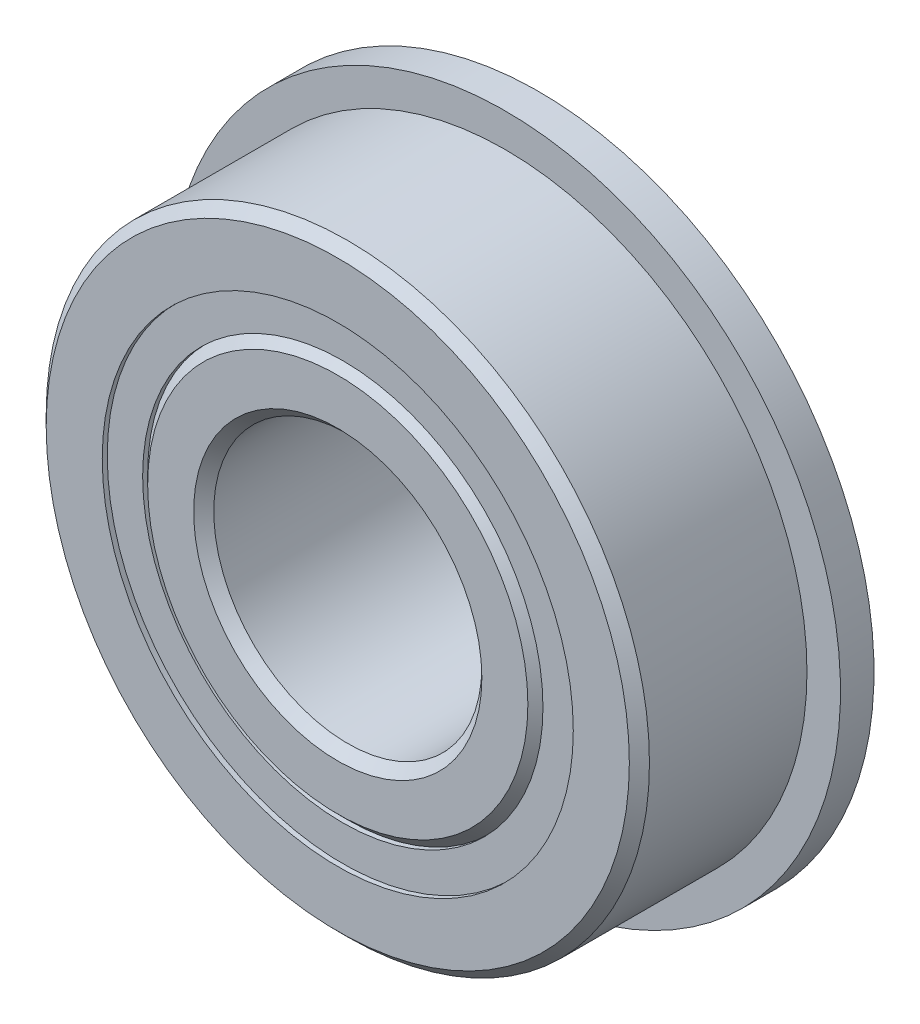
from build123d import *

# Parameters (mm, degrees)
CIRPATTERN1_COUNT = 12
SKETCH5_W         = 2.248094269
SKETCH5_H         = 1.674725274
SKETCH6_W         = 1.5875
SKETCH6_H         = 4.718887363


with BuildPart() as part:
    # Sketch1 → Revolve1 (revolve)
    with BuildSketch(Plane(origin=(0, 0, 0), x_dir=(0, 0, -1), z_dir=(1, 0, 0)), mode=Mode.PRIVATE) as revolve1_sk:
        with BuildLine():
            Line((4.28625, 14.2875), (-4.28625, 14.2875))
            Line((-4.28625, 14.2875), (-4.7625, 13.81125))
            Line((-4.7625, 13.81125), (-4.7625, 11.156112637))
            Line((-4.7625, 11.156112637), (-2.116666667, 11.156112637))
            ThreePointArc((-2.116666667, 11.156112637), (0, 12.595030731), (2.116666667, 11.156112637))
            Line((2.116666667, 11.156112637), (4.7625, 11.156112637))
            Line((4.7625, 11.156112637), (4.7625, 13.81125))
            Line((4.7625, 13.81125), (4.28625, 14.2875))
        make_face()
    revolve(revolve1_sk.sketch.rotate(Axis((0, 0, 4.7625), (0, 0, -1)), 90), axis=Axis((0, 0, 4.7625), (0, 0, -1)))  # turned: the seam where the file's is

    # Sketch6 → Revolve6 (revolve)
    with BuildSketch(Plane(origin=(0, 0, 0), x_dir=(0, 0, -1), z_dir=(1, 0, 0)), mode=Mode.PRIVATE) as revolve6_sk:
        with Locations((3.96875, 13.515556319)):
            Rectangle(SKETCH6_W, SKETCH6_H)
    revolve(revolve6_sk.sketch.rotate(Axis((0, 0, -4.7625), (0, 0, 1)), 270), axis=Axis((0, 0, -4.7625), (0, 0, 1)))  # turned: the seam where the file's is


with BuildPart() as body_2:
    # Sketch3 → Revolve3 (revolve)
    with BuildSketch(Plane(origin=(0, 0, 0), x_dir=(0, 0, -1), z_dir=(1, 0, 0)), mode=Mode.PRIVATE) as revolve3_sk:
        with BuildLine():
            Line((-4.7625, 6.82625), (-4.7625, 9.005137363))
            Line((-4.7625, 9.005137363), (-4.28625, 9.481387363))
            Line((-4.28625, 9.481387363), (-2.116666667, 9.481387363))
            ThreePointArc((-2.116666667, 9.481387363), (0, 8.042469269), (2.116666667, 9.481387363))
            Line((2.116666667, 9.481387363), (5.87375, 9.481387363))
            Line((5.87375, 9.481387363), (6.35, 9.005137363))
            Line((6.35, 9.005137363), (6.35, 6.82625))
            Line((6.35, 6.82625), (5.87375, 6.35))
            Line((5.87375, 6.35), (-4.28625, 6.35))
            Line((-4.28625, 6.35), (-4.7625, 6.82625))
        make_face()
    revolve(revolve3_sk.sketch.rotate(Axis((0, 0, 4.7625), (0, 0, -1)), 90), axis=Axis((0, 0, 4.7625), (0, 0, -1)))  # turned: the seam where the file's is


with BuildPart() as body_3:
    # Sketch4 → Revolve4 (revolve)
    with BuildSketch(Plane(origin=(0, 0, 0), x_dir=(0, 0, -1), z_dir=(1, 0, 0))):
        with BuildLine():
            Line((-2.276280731, 10.31875), (2.276280731, 10.31875))
            ThreePointArc((2.276280731, 10.31875), (0, 12.595030731), (-2.276280731, 10.31875))
        make_face()
    revolve(axis=Axis((0, 10.31875, 2.276280731), (0, 0, -1)))


with BuildPart() as cirpattern1_1:
    # CirPattern1: pattern copy
    add(body_3.part.rotate(Axis((0, 0, 0), (0, 0, 1)), 1 * 360 / CIRPATTERN1_COUNT))


with BuildPart() as cirpattern1_2:
    # CirPattern1: pattern copy
    add(body_3.part.rotate(Axis((0, 0, 0), (0, 0, 1)), 2 * 360 / CIRPATTERN1_COUNT))


with BuildPart() as cirpattern1_3:
    # CirPattern1: pattern copy
    add(body_3.part.rotate(Axis((0, 0, 0), (0, 0, 1)), 3 * 360 / CIRPATTERN1_COUNT))


with BuildPart() as cirpattern1_4:
    # CirPattern1: pattern copy
    add(body_3.part.rotate(Axis((0, 0, 0), (0, 0, 1)), 4 * 360 / CIRPATTERN1_COUNT))


with BuildPart() as cirpattern1_5:
    # CirPattern1: pattern copy
    add(body_3.part.rotate(Axis((0, 0, 0), (0, 0, 1)), 5 * 360 / CIRPATTERN1_COUNT))


with BuildPart() as cirpattern1_6:
    # CirPattern1: pattern copy
    add(body_3.part.rotate(Axis((0, 0, 0), (0, 0, 1)), 6 * 360 / CIRPATTERN1_COUNT))


with BuildPart() as cirpattern1_7:
    # CirPattern1: pattern copy
    add(body_3.part.rotate(Axis((0, 0, 0), (0, 0, 1)), 7 * 360 / CIRPATTERN1_COUNT))


with BuildPart() as cirpattern1_8:
    # CirPattern1: pattern copy
    add(body_3.part.rotate(Axis((0, 0, 0), (0, 0, 1)), 8 * 360 / CIRPATTERN1_COUNT))


with BuildPart() as cirpattern1_9:
    # CirPattern1: pattern copy
    add(body_3.part.rotate(Axis((0, 0, 0), (0, 0, 1)), 9 * 360 / CIRPATTERN1_COUNT))


with BuildPart() as cirpattern1_10:
    # CirPattern1: pattern copy
    add(body_3.part.rotate(Axis((0, 0, 0), (0, 0, 1)), 10 * 360 / CIRPATTERN1_COUNT))


with BuildPart() as cirpattern1_11:
    # CirPattern1: pattern copy
    add(body_3.part.rotate(Axis((0, 0, 0), (0, 0, 1)), 11 * 360 / CIRPATTERN1_COUNT))


with BuildPart() as body_15:
    # Sketch5 → Revolve5 (revolve)
    with BuildSketch(Plane(origin=(0, 0, 0), x_dir=(0, 0, -1), z_dir=(1, 0, 0)), mode=Mode.PRIVATE) as revolve5_sk:
        with Locations((-3.400327865, 10.31875)):
            Rectangle(SKETCH5_W, SKETCH5_H)
        with Locations((3.400327865, 10.31875)):
            Rectangle(SKETCH5_W, SKETCH5_H)
    revolve(revolve5_sk.sketch.rotate(Axis((0, 0, 4.7625), (0, 0, -1)), 90), axis=Axis((0, 0, 4.7625), (0, 0, -1)))  # turned: the seam where the file's is


solid = Compound([part.part, body_2.part, body_3.part, cirpattern1_1.part, cirpattern1_2.part, cirpattern1_3.part, cirpattern1_4.part, cirpattern1_5.part, cirpattern1_6.part, cirpattern1_7.part, cirpattern1_8.part, cirpattern1_9.part, cirpattern1_10.part, cirpattern1_11.part, body_15.part])
